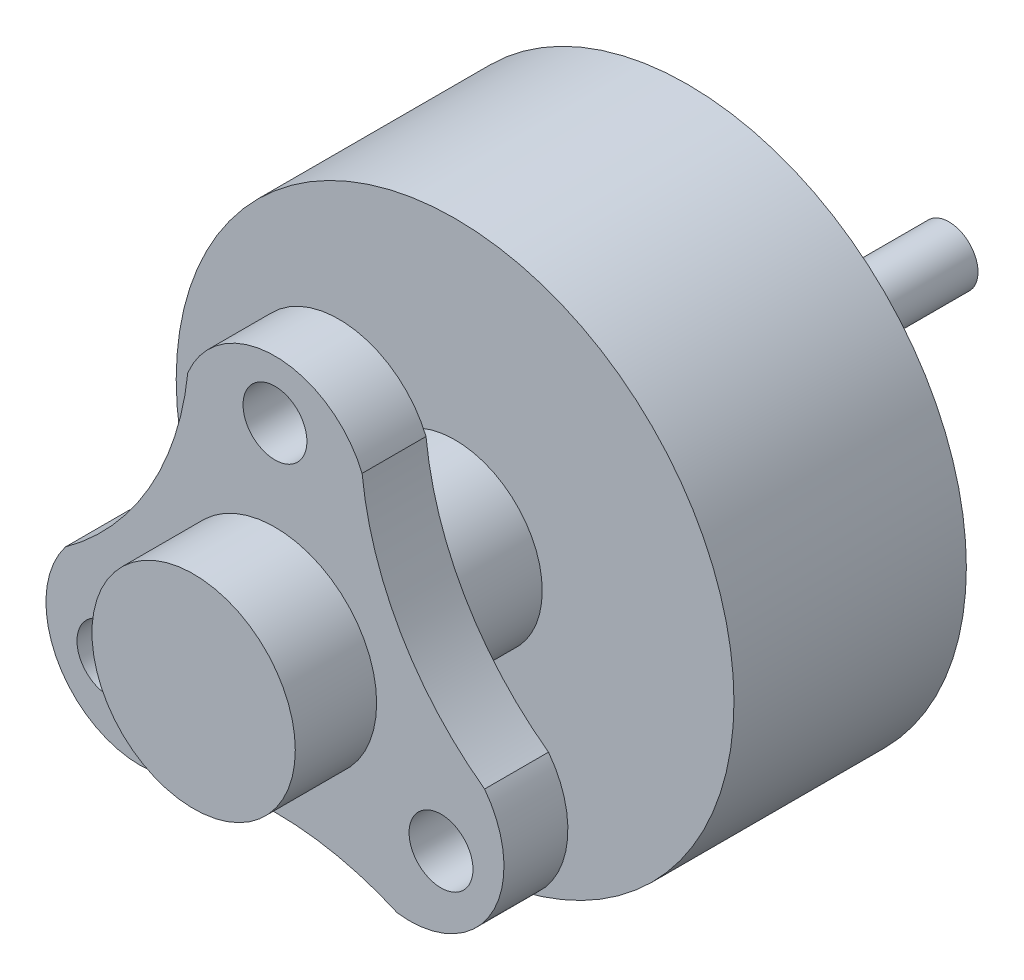
from build123d import *

# Parameters (mm, degrees)
SKETCH1_R                   = 4.8
BOSS_EXTRUDE1_DEPTH         = 4
SKETCH3_R                   = 1.5
BOSS_EXTRUDE2_DEPTH         = 2
BOSS_EXTRUDE3_DEPTH         = 1.1
M1_4X0_3_TAPPED_HOLE2_D     = 1.1
M1_4X0_3_TAPPED_HOLE2_DEPTH = 1.1
SKETCH14_R                  = 0.5
BOSS_EXTRUDE4_DEPTH         = 4.5
SKETCH15_R                  = 1.75
BOSS_EXTRUDE5_DEPTH         = 1.4


with BuildPart() as part:
    # Sketch1 → Boss-Extrude1 (new body)
    with BuildSketch(Plane.XY):
        Circle(SKETCH1_R)
    extrude(amount=BOSS_EXTRUDE1_DEPTH)

    # Sketch3 → Boss-Extrude2 (add)
    with BuildSketch(Plane.XY.offset(4)):
        Circle(SKETCH3_R)
    extrude(amount=BOSS_EXTRUDE2_DEPTH)

    # Sketch4 → Boss-Extrude3 (add)
    with BuildSketch(Plane.XY.offset(6)):
        with BuildLine():
            Line((0, 3.3), (0, 2.5))
            ThreePointArc((0, 2.5), (1.250000026, 2.165063495), (2.165063539, 1.249999948))
            ThreePointArc((2.165063539, 1.249999948), (1.724566258, 2.23997367), (1.5, 3.3))
            Line((1.5, 3.3), (0, 3.3))
        make_face()
        with BuildLine():
            Line((0, 4.3), (0, 3.3))
            Line((0, 3.3), (1.5, 3.3))
            ThreePointArc((1.5, 3.3), (0.901387819, 4.027081728), (0, 4.3))
        make_face()
        with BuildLine():
            Line((-1.5, 3.3), (0, 3.3))
            Line((0, 3.3), (0, 4.3))
            ThreePointArc((0, 4.3), (-0.901387819, 4.027081728), (-1.5, 3.3))
        make_face()
        with BuildLine():
            ThreePointArc((-2.165063492, 1.25000003), (-1.249999985, 2.165063518), (0, 2.5))
            Line((0, 2.5), (0, 3.3))
            Line((0, 3.3), (-1.5, 3.3))
            ThreePointArc((-1.5, 3.3), (-1.724566244, 2.239973715), (-2.165063492, 1.25000003))
        make_face()
        with BuildLine():
            ThreePointArc((-1.299038106, 0.75), (-0.75, 1.299038106), (0, 1.5))
            Line((0, 1.5), (0, 2.5))
            ThreePointArc((0, 2.5), (-1.249999985, 2.165063518), (-2.165063492, 1.25000003))
            ThreePointArc((-2.165063492, 1.25000003), (-2.5, 1.7e-08), (-2.165063509, -1.25))
            Line((-2.165063509, -1.25), (-1.299038106, -0.75))
            ThreePointArc((-1.299038106, -0.75), (-1.5, 0), (-1.299038106, 0.75))
        make_face()
        with BuildLine():
            Line((0, 2.5), (0, 1.5))
            ThreePointArc((0, 1.5), (0.75, 1.299038106), (1.299038106, 0.75))
            ThreePointArc((1.299038106, 0.75), (1.448888739, 0.388228568), (1.5, 0))
            ThreePointArc((1.5, 0), (1.448888739, -0.388228568), (1.299038106, -0.75))
            Line((1.299038106, -0.75), (2.165063509, -1.25))
            ThreePointArc((2.165063509, -1.25), (2.414814566, -0.647047613), (2.5, 0))
            ThreePointArc((2.5, 0), (2.414814573, 0.647047584), (2.165063539, 1.249999948))
            ThreePointArc((2.165063539, 1.249999948), (1.250000026, 2.165063495), (0, 2.5))
        make_face()
        with BuildLine():
            Line((1.299038106, 0.75), (0, 0))
            Line((0, 0), (1.299038106, -0.75))
            ThreePointArc((1.299038106, -0.75), (1.448888739, -0.388228568), (1.5, 0))
            ThreePointArc((1.5, 0), (1.448888739, 0.388228568), (1.299038106, 0.75))
        make_face()
        with BuildLine():
            Line((0, 1.5), (0, 0))
            Line((0, 0), (1.299038106, 0.75))
            ThreePointArc((1.299038106, 0.75), (0.75, 1.299038106), (0, 1.5))
        make_face()
        with BuildLine():
            Line((-1.299038106, 0.75), (0, 0))
            Line((0, 0), (0, 1.5))
            ThreePointArc((0, 1.5), (-0.75, 1.299038106), (-1.299038106, 0.75))
        make_face()
        with BuildLine():
            Line((-1.299038106, -0.75), (0, 0))
            Line((0, 0), (-1.299038106, 0.75))
            ThreePointArc((-1.299038106, 0.75), (-1.5, 0), (-1.299038106, -0.75))
        make_face()
        with BuildLine():
            Line((0, -1.5), (0, 0))
            Line((0, 0), (-1.299038106, -0.75))
            ThreePointArc((-1.299038106, -0.75), (-0.75, -1.299038106), (0, -1.5))
        make_face()
        with BuildLine():
            Line((1.299038106, -0.75), (0, 0))
            Line((0, 0), (0, -1.5))
            ThreePointArc((0, -1.5), (0.75, -1.299038106), (1.299038106, -0.75))
        make_face()
        with BuildLine():
            ThreePointArc((0, -1.5), (-0.75, -1.299038106), (-1.299038106, -0.75))
            Line((-1.299038106, -0.75), (-2.165063509, -1.25))
            ThreePointArc((-2.165063509, -1.25), (-1.25, -2.165063509), (0, -2.5))
            ThreePointArc((0, -2.5), (1.25, -2.165063509), (2.165063509, -1.25))
            Line((2.165063509, -1.25), (1.299038106, -0.75))
            ThreePointArc((1.299038106, -0.75), (0.75, -1.299038106), (0, -1.5))
        make_face()
        with BuildLine():
            ThreePointArc((2.5, 0), (2.414814566, -0.647047613), (2.165063509, -1.25))
            Line((2.165063509, -1.25), (2.857883832, -1.65))
            Line((2.857883832, -1.65), (3.607883832, -0.350961894))
            ThreePointArc((3.607883832, -0.350961894), (2.802157271, 0.373531311), (2.165063539, 1.249999948))
            ThreePointArc((2.165063539, 1.249999948), (2.414814573, 0.647047584), (2.5, 0))
        make_face()
        with BuildLine():
            Line((2.857883832, -1.65), (2.165063509, -1.25))
            ThreePointArc((2.165063509, -1.25), (1.25, -2.165063509), (0, -2.5))
            ThreePointArc((0, -2.5), (1.077591002, -2.613505032), (2.107883832, -2.949038106))
            Line((2.107883832, -2.949038106), (2.857883832, -1.65))
        make_face()
        with BuildLine():
            ThreePointArc((0, -2.5), (-1.25, -2.165063509), (-2.165063509, -1.25))
            Line((-2.165063509, -1.25), (-2.857883832, -1.65))
            Line((-2.857883832, -1.65), (-2.107883832, -2.949038106))
            ThreePointArc((-2.107883832, -2.949038106), (-1.077591002, -2.613505032), (0, -2.5))
        make_face()
        with BuildLine():
            Line((-2.857883832, -1.65), (-2.165063509, -1.25))
            ThreePointArc((-2.165063509, -1.25), (-2.5, 1.7e-08), (-2.165063492, 1.25000003))
            ThreePointArc((-2.165063492, 1.25000003), (-2.80215724, 0.373531346), (-3.607883832, -0.350961894))
            Line((-3.607883832, -0.350961894), (-2.857883832, -1.65))
        make_face()
        with BuildLine():
            Line((-3.723909236, -2.15), (-2.857883832, -1.65))
            Line((-2.857883832, -1.65), (-3.607883832, -0.350961894))
            ThreePointArc((-3.607883832, -0.350961894), (-3.938248989, -1.232916114), (-3.723909236, -2.15))
        make_face()
        with BuildLine():
            Line((-2.107883832, -2.949038106), (-2.857883832, -1.65))
            Line((-2.857883832, -1.65), (-3.723909236, -2.15))
            ThreePointArc((-3.723909236, -2.15), (-3.03686117, -2.794165614), (-2.107883832, -2.949038106))
        make_face()
        with BuildLine():
            Line((3.723909236, -2.15), (2.857883832, -1.65))
            Line((2.857883832, -1.65), (2.107883832, -2.949038106))
            ThreePointArc((2.107883832, -2.949038106), (3.03686117, -2.794165614), (3.723909236, -2.15))
        make_face()
        with BuildLine():
            Line((3.607883832, -0.350961894), (2.857883832, -1.65))
            Line((2.857883832, -1.65), (3.723909236, -2.15))
            ThreePointArc((3.723909236, -2.15), (3.938248989, -1.232916114), (3.607883832, -0.350961894))
        make_face()
    extrude(amount=BOSS_EXTRUDE3_DEPTH)

    # M1.4x0.3 Tapped Hole2
    with Locations(Plane.XY.offset(7.1)):
        with Locations((2.857884156, -1.649999841), (-2.85788391, -1.649999841), (0, 3.300000228)):
            Hole(M1_4X0_3_TAPPED_HOLE2_D / 2, depth=M1_4X0_3_TAPPED_HOLE2_DEPTH)

    # Sketch14 → Boss-Extrude4 (add)
    with BuildSketch(Plane(origin=(0, 0, 0), x_dir=(-1, 0, 0), z_dir=(0, 0, -1))):
        Circle(SKETCH14_R)
    extrude(amount=BOSS_EXTRUDE4_DEPTH)

    # Sketch15 → Boss-Extrude5 (add)
    with BuildSketch(Plane.XY.offset(7.1)):
        Circle(SKETCH15_R)
    extrude(amount=BOSS_EXTRUDE5_DEPTH)


solid = part.part
